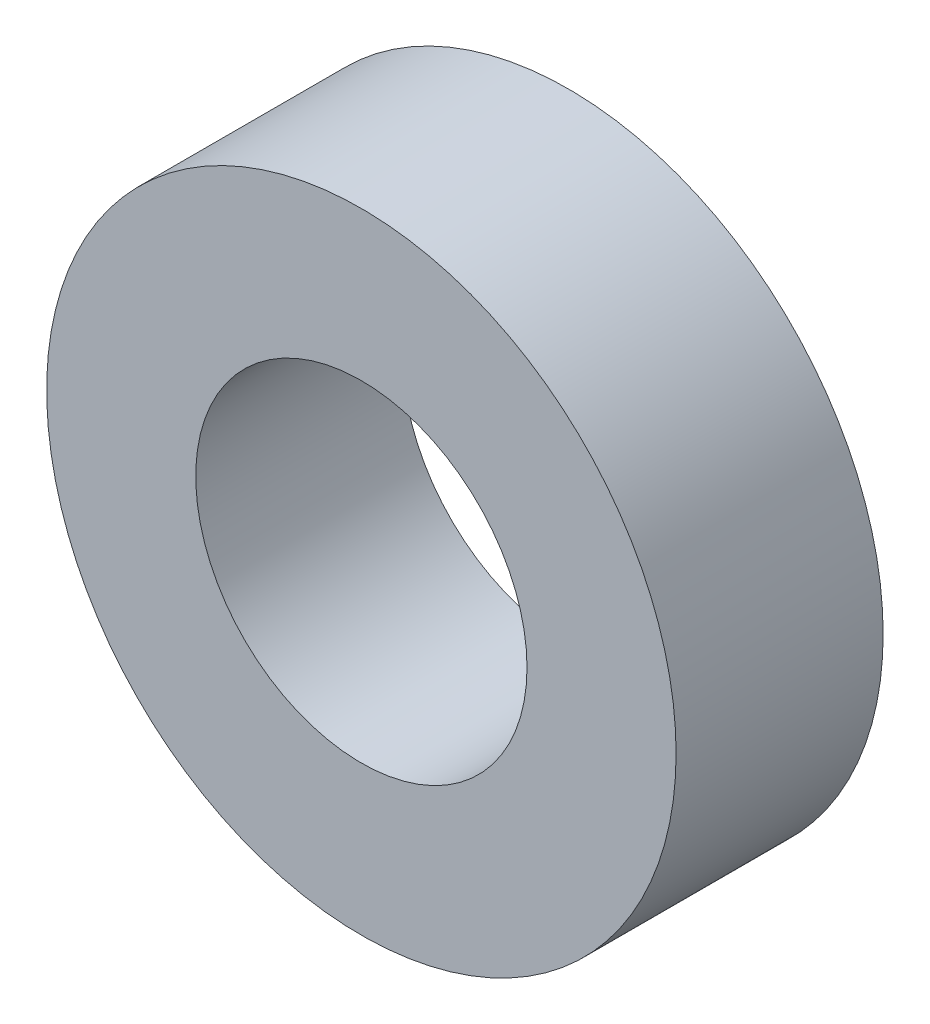
from build123d import *

# Parameters (mm, degrees)
SKETCH1_W = 2.25
SKETCH1_H = 3.125


with BuildPart() as part:
    # Sketch1 → Revolve1 (revolve)
    with BuildSketch(Plane(origin=(0, 0, 0), x_dir=(1, 0, 0), z_dir=(0, 1, 0))):
        with Locations((3.625, 0)):
            Rectangle(SKETCH1_W, SKETCH1_H)
    revolve(axis=Axis((0, 0, -1.5625), (0, 0, 1)))


solid = part.part
